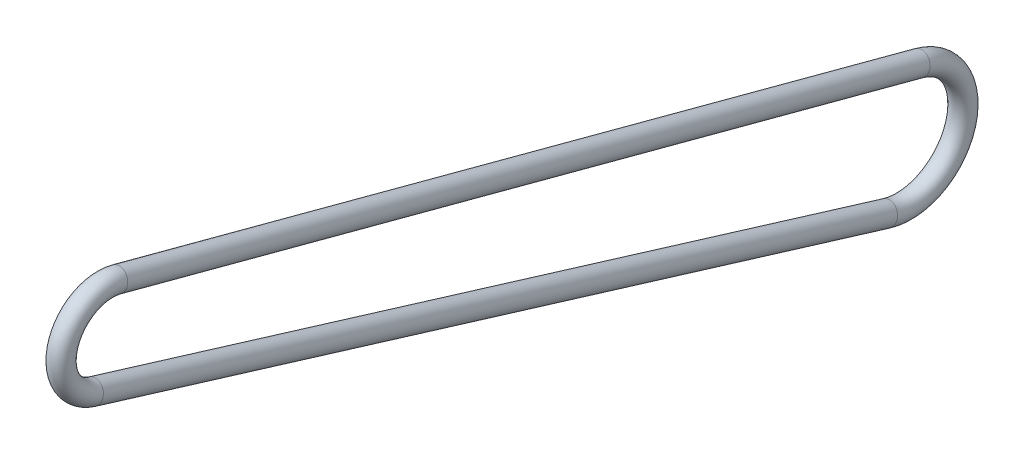
from build123d import *

# Parameters (mm, degrees)
SKETCH2_R = 1.984375


with BuildPart() as part:
    # Sweep1: sweep along a path in Sketch1
    with BuildLine(Plane(origin=(0, 0, 0), x_dir=(0, 0, -1), z_dir=(1, 0, 0))) as sweep1_path:
        Line((2.117981875, 7.942530188), (151.198749113, -31.811849763))
        ThreePointArc((151.198749113, -31.811849763), (158.940303021, -45.465708952), (145.149198701, -52.960038095))
        Line((145.149198701, -52.960038095), (-2.402723407, -7.861078376))
        ThreePointArc((-2.402723407, -7.861078376), (-7.903086761, 2.260719501), (2.117981875, 7.942530188))
    # Sketch2 → Sweep1 (sweep)
    with BuildSketch(Plane(origin=(0, 7.942530188, -2.117981875), x_dir=(-1, 0, 0), z_dir=(0, -0.25765967762823605, -0.9662357323782399))):
        Circle(SKETCH2_R)
    sweep(path=sweep1_path.line)


solid = part.part
